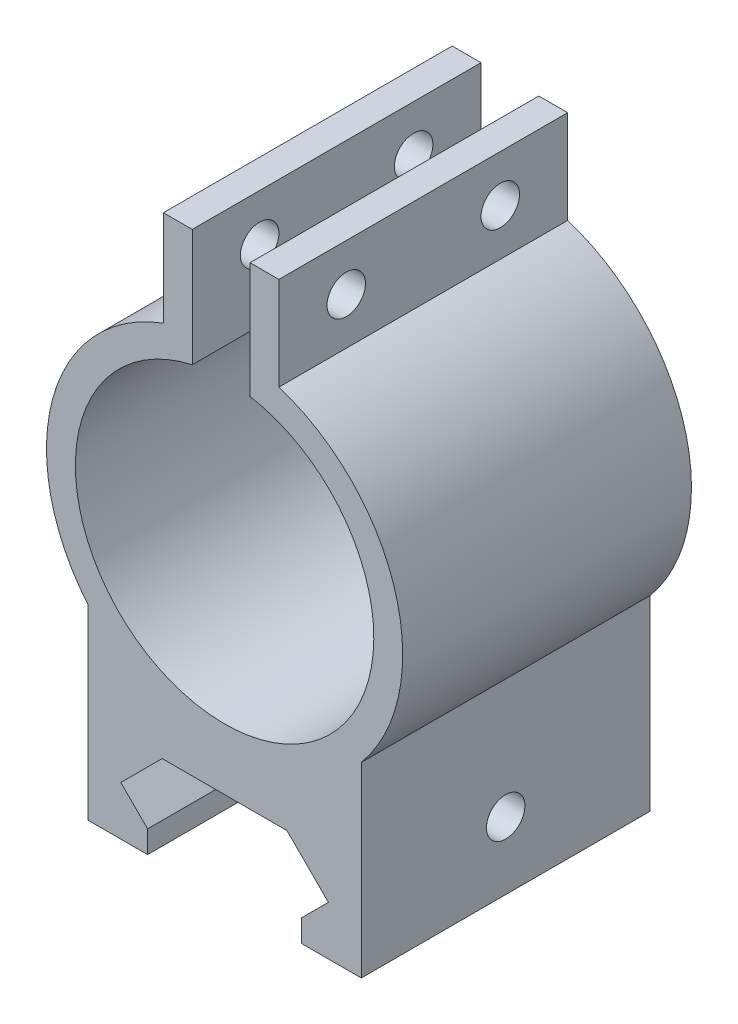
from build123d import *

# Parameters (mm, degrees)
BOSS_EXTRUDE1_DEPTH = 30
SKETCH2_R           = 2
CUT_EXTRUDE1_DEPTH  = 25.140587276
SKETCH3_R           = 2
CUT_EXTRUDE2_DEPTH  = 33.7


with BuildPart() as part:
    # Sketch1 → Boss-Extrude1 (new body)
    with BuildSketch(Plane.XY):
        with BuildLine():
            Line((2.640587276, 55.058478526), (2.640587276, 61.071909479))
            Line((2.640587276, 61.071909479), (5.640587276, 61.071909479))
            Line((5.640587276, 61.071909479), (5.640587276, 51.377039696))
            ThreePointArc((5.640587276, 51.377039696), (17.766153021, 38.916765877), (14.2, 21.9))
            Line((14.2, 21.9), (14.2, 2.5))
            Line((14.2, 2.5), (11.082842712, 2.5))
            Line((11.082842712, 2.5), (8, 2.5))
            Line((8, 2.5), (8, 4.817157288))
            Line((8, 4.817157288), (10.782842712, 7.6))
            Line((10.782842712, 7.6), (6.482842712, 11.9))
            Line((6.482842712, 11.9), (-6.482842712, 11.9))
            Line((-6.482842712, 11.9), (-10.782842712, 7.6))
            Line((-10.782842712, 7.6), (-8, 4.817157288))
            Line((-8, 4.817157288), (-8, 2.5))
            Line((-8, 2.5), (-11.082842712, 2.5))
            Line((-11.082842712, 2.5), (-14.2, 2.5))
            Line((-14.2, 2.5), (-14.2, 21.9))
            ThreePointArc((-14.2, 21.9), (-17.868360087, 38.550789704), (-6.359412724, 51.130527146))
            Line((-6.359412724, 51.130527146), (-6.359412724, 61.069189213))
            Line((-6.359412724, 61.069189213), (-3.359412724, 61.069189213))
            Line((-3.359412724, 61.069189213), (-3.359412724, 55.069189213))
            Line((-3.359412724, 55.069189213), (-3.359412724, 48.889476621))
            ThreePointArc((-3.359412724, 48.889476621), (0.366343929, 18.262238644), (2.640587276, 49.0313268))
            Line((2.640587276, 49.0313268), (2.640587276, 55.058478526))
        make_face()
    extrude(amount=BOSS_EXTRUDE1_DEPTH)

    # Sketch2 → Cut-Extrude1 (cut, through all)
    with BuildSketch(Plane(origin=(5.640587276, 0, 0), x_dir=(0, 0, -1), z_dir=(1, 0, 0))):
        with Locations(Location((-7, 56.224474587, 0), (0, 0, 270))):  # turned: the seam where the file's is
            Circle(SKETCH2_R)
        with Locations(Location((-23, 56.224474587, 0), (0, 0, 270))):  # turned: the seam where the file's is
            Circle(SKETCH2_R)
    extrude(amount=-CUT_EXTRUDE1_DEPTH, mode=Mode.SUBTRACT)

    # Sketch3 → Cut-Extrude2 (cut, through all)
    with BuildSketch(Plane(origin=(14.2, 0, 0), x_dir=(0, 0, -1), z_dir=(1, 0, 0))):
        with Locations(Location((-15, 9.5, 0), (0, 0, 90))):  # turned: the seam where the file's is
            Circle(SKETCH3_R)
    extrude(amount=-CUT_EXTRUDE2_DEPTH, mode=Mode.SUBTRACT)


solid = part.part
